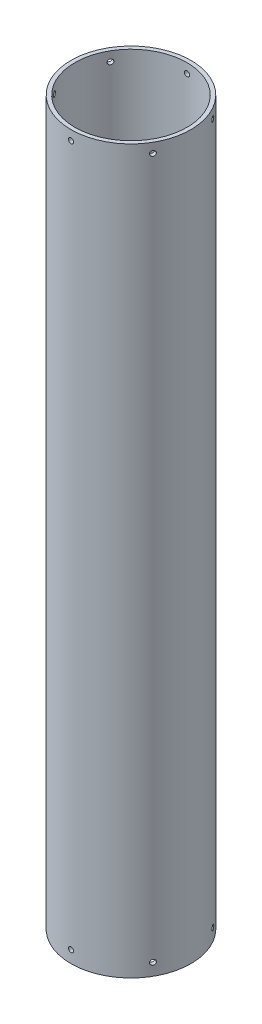
from build123d import *

# Parameters (mm, degrees)
SKETCH2_R           = 19.25
SKETCH2_R_2         = 18
BOSS_EXTRUDE1_DEPTH = 231.82
SKETCH3_R           = 0.815
CUT_EXTRUDE2_DEPTH  = 231.82
CIRPATTERN3_COUNT   = 6
SKETCH4_R           = 0.815
CUT_EXTRUDE3_DEPTH  = 231.82
CIRPATTERN4_COUNT   = 6


with BuildPart() as part:
    # Sketch2 → Boss-Extrude1 (new body)
    with BuildSketch(Plane(origin=(0, 0, 0), x_dir=(1, 0, 0), z_dir=(0, 1, 0))):
        Circle(SKETCH2_R)
        Circle(SKETCH2_R_2, mode=Mode.SUBTRACT)
    extrude(amount=BOSS_EXTRUDE1_DEPTH)

    # Sketch3 → Cut-Extrude2 (cut)
    with BuildSketch(Plane.XY):
        with Locations((0, 3.92)):
            Circle(SKETCH3_R)
    cut_extrude2 = extrude(amount=-CUT_EXTRUDE2_DEPTH, mode=Mode.SUBTRACT)

    # CirPattern3: Cut-Extrude2 ×6 about axis
    cirpattern3_axis = Axis((0, 231.82, 0), (0, -1, 0))
    for i in range(1, CIRPATTERN3_COUNT):
        add(cut_extrude2.rotate(cirpattern3_axis, i * 360 / CIRPATTERN3_COUNT), mode=Mode.SUBTRACT)

    # Sketch4 → Cut-Extrude3 (cut)
    with BuildSketch(Plane.XY):
        with Locations((0, 228.73)):
            Circle(SKETCH4_R)
    cut_extrude3 = extrude(amount=CUT_EXTRUDE3_DEPTH, mode=Mode.SUBTRACT)

    # CirPattern4: Cut-Extrude3 ×6 about axis
    cirpattern4_axis = Axis((0, 231.82, 0), (0, -1, 0))
    for i in range(1, CIRPATTERN4_COUNT):
        add(cut_extrude3.rotate(cirpattern4_axis, i * 360 / CIRPATTERN4_COUNT), mode=Mode.SUBTRACT)


solid = part.part
